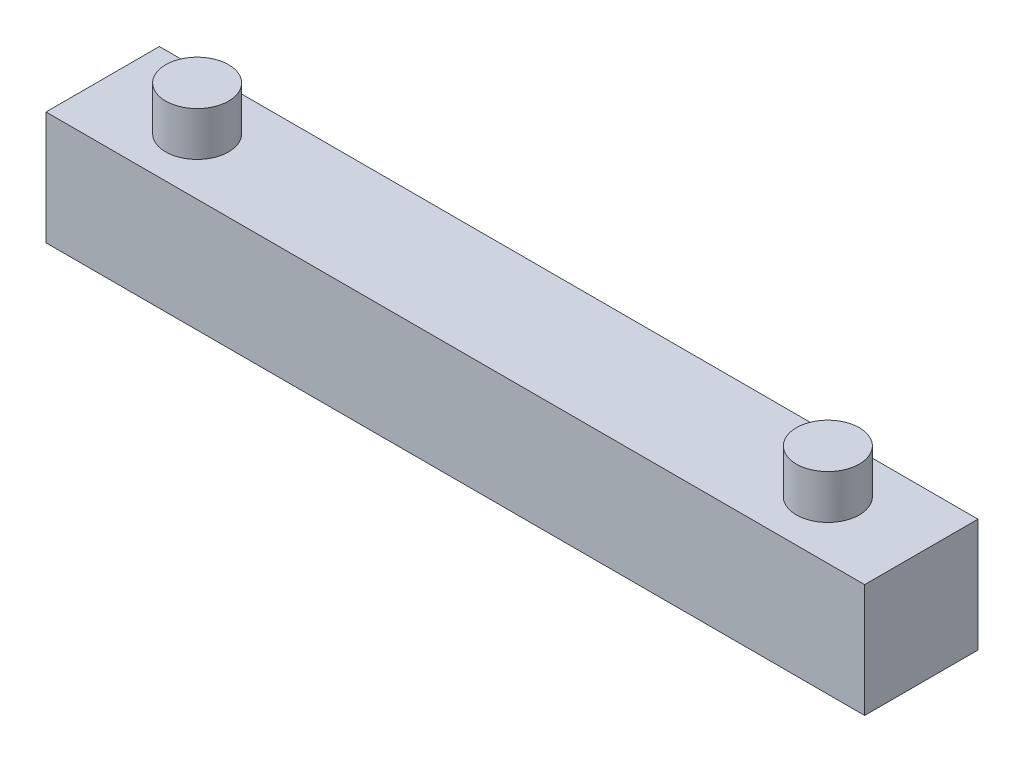
from build123d import *

# Parameters (mm, degrees)
SKETCH1_W           = 65
SKETCH1_H           = 9
BOSS_EXTRUDE1_DEPTH = 9
SKETCH2_R           = 2.5
BOSS_EXTRUDE2_DEPTH = 3.5


with BuildPart() as part:
    # Sketch1 → Boss-Extrude1 (new body)
    with BuildSketch(Plane.XY):
        with Locations((32.5, 4.5)):
            Rectangle(SKETCH1_W, SKETCH1_H)
    extrude(amount=BOSS_EXTRUDE1_DEPTH)

    # Sketch2 → Boss-Extrude2 (add)
    with BuildSketch(Plane(origin=(0, 9, 0), x_dir=(1, 0, 0), z_dir=(0, 1, 0))):
        with Locations((7.500462168, -4.5)):
            Circle(SKETCH2_R)
        with Locations((57.500401887, -4.422358915)):
            Circle(SKETCH2_R)
    extrude(amount=BOSS_EXTRUDE2_DEPTH)


solid = part.part
